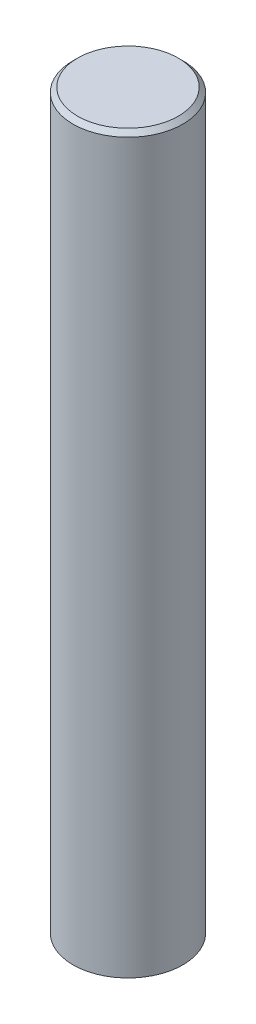
from build123d import *

# Parameters (mm, degrees)
SKETCH2_R           = 12
BOSS_EXTRUDE1_DEPTH = 160
CHAMFER1_SIZE       = 1


with BuildPart() as part:
    # Sketch2 → Boss-Extrude1 (new body)
    with BuildSketch(Plane(origin=(0, 0, 0), x_dir=(1, 0, 0), z_dir=(0, 1, 0))):
        Circle(SKETCH2_R)
    extrude(amount=BOSS_EXTRUDE1_DEPTH)

    # Chamfer1
    chamfer1_edges = [part.edges().sort_by_distance(p)[0] for p in [
        (-12, 160, 0),
    ]]
    chamfer(chamfer1_edges, length=CHAMFER1_SIZE)


solid = part.part
